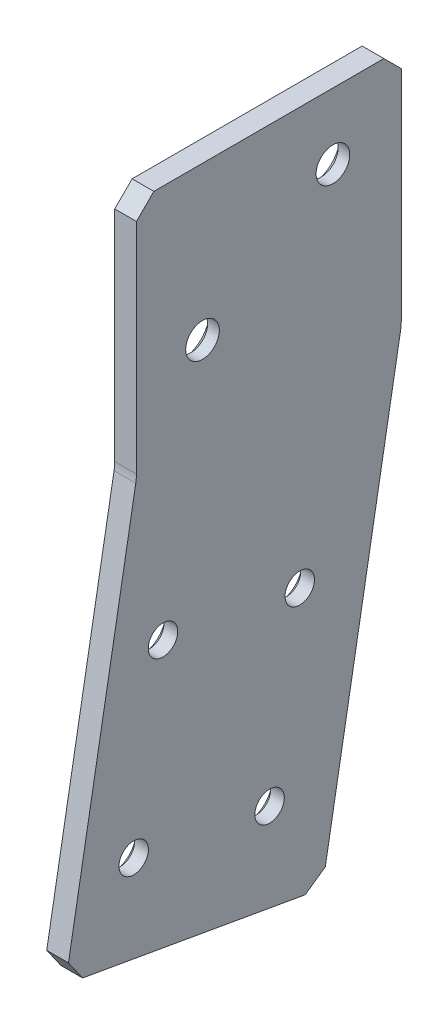
from build123d import *

# Parameters (mm, degrees)
BOSS_EXTRUDE1_DEPTH                               = 3.175
FILLET1_R                                         = 6.35
CSK_FOR_6_FLAT_HEAD_MACHINE_SCREW_100_D           = 4.3053
CSK_FOR_6_FLAT_HEAD_MACHINE_SCREW_100_CSINK_D     = 7.0866
CSK_FOR_6_FLAT_HEAD_MACHINE_SCREW_100_CSINK_ANGLE = 100
CSK_FOR_8_FLAT_HEAD_MACHINE_SCREW_2_COUNT         = 2
CSK_FOR_8_FLAT_HEAD_MACHINE_SCREW_2_PITCH         = 22.895250599
CHAMFER1_SIZE                                     = 2.54


with BuildPart() as part:
    # Sketch1 → Boss-Extrude1 (new body)
    with BuildSketch(Plane.ZY.offset(-5.035827965)):
        Polygon((-147.77562455, 230.070458845), (-159.314588786, 295.511176933), (-159.314588786, 330.563176933), (-120.626834873, 330.563176933), (-120.626834873, 295.511176933), (-110.25444916, 236.686454414), align=None)
    extrude(amount=BOSS_EXTRUDE1_DEPTH)

    # Fillet1
    fillet1_edges = [part.edges().sort_by_distance(p)[0] for p in [
        (3.448327965, 295.511176933, -159.314588786),
        (3.448327965, 295.511176933, -120.626834873),
    ]]
    fillet(fillet1_edges, radius=FILLET1_R)

    # CSK for #6 Flat Head Machine Screw (100)1 (through all)
    with Locations(Plane.ZY.offset(-1.860827965)):
        with Locations((-124.504125043, 273.139415456), (-144.485224025, 269.724179148), (-140.075144867, 244.324179148), (-120.227402214, 247.716621746)):
            CounterSinkHole(CSK_FOR_6_FLAT_HEAD_MACHINE_SCREW_100_D / 2, CSK_FOR_6_FLAT_HEAD_MACHINE_SCREW_100_CSINK_D / 2, counter_sink_angle=CSK_FOR_6_FLAT_HEAD_MACHINE_SCREW_100_CSINK_ANGLE)

    # Sketch5 → CSK for #8 Flat Head Machine Screw (100)1 (revolve, cut)
    with BuildSketch(Plane(origin=(1.860827965, 320.911176933, -149.328834873), x_dir=(0, 0, 1), z_dir=(0, 1, 0))):
        Polygon((0, 0), (0, 3.175), (2.45745, 3.175), (2.45745, 1.475934296), (4.2164, 0), align=None)
    csk_for_8_flat_head_machine_screw_100 = revolve(axis=Axis((-4.489172035, 320.911176933, -149.328834873), (1, 0, 0)), mode=Mode.SUBTRACT)

    # CSK for _8 Flat Head Machine Screw _ 2: CSK for #8 Flat Head Machine Screw (100)1 ×2
    with Locations(*[Vector(0, -0.554700196, 0.832050294) * (i * CSK_FOR_8_FLAT_HEAD_MACHINE_SCREW_2_PITCH) for i in range(1, CSK_FOR_8_FLAT_HEAD_MACHINE_SCREW_2_COUNT)]):
        add(csk_for_8_flat_head_machine_screw_100, mode=Mode.SUBTRACT)

    # Chamfer1
    chamfer1_edges = [part.edges().sort_by_distance(p)[0] for p in [
        (3.448327965, 230.070458845, -147.77562455),
        (3.448327965, 330.563176933, -159.314588786),
        (3.448327965, 330.563176933, -120.626834873),
        (3.448327965, 236.686454414, -110.25444916),
    ]]
    chamfer(chamfer1_edges, length=CHAMFER1_SIZE)


solid = part.part
